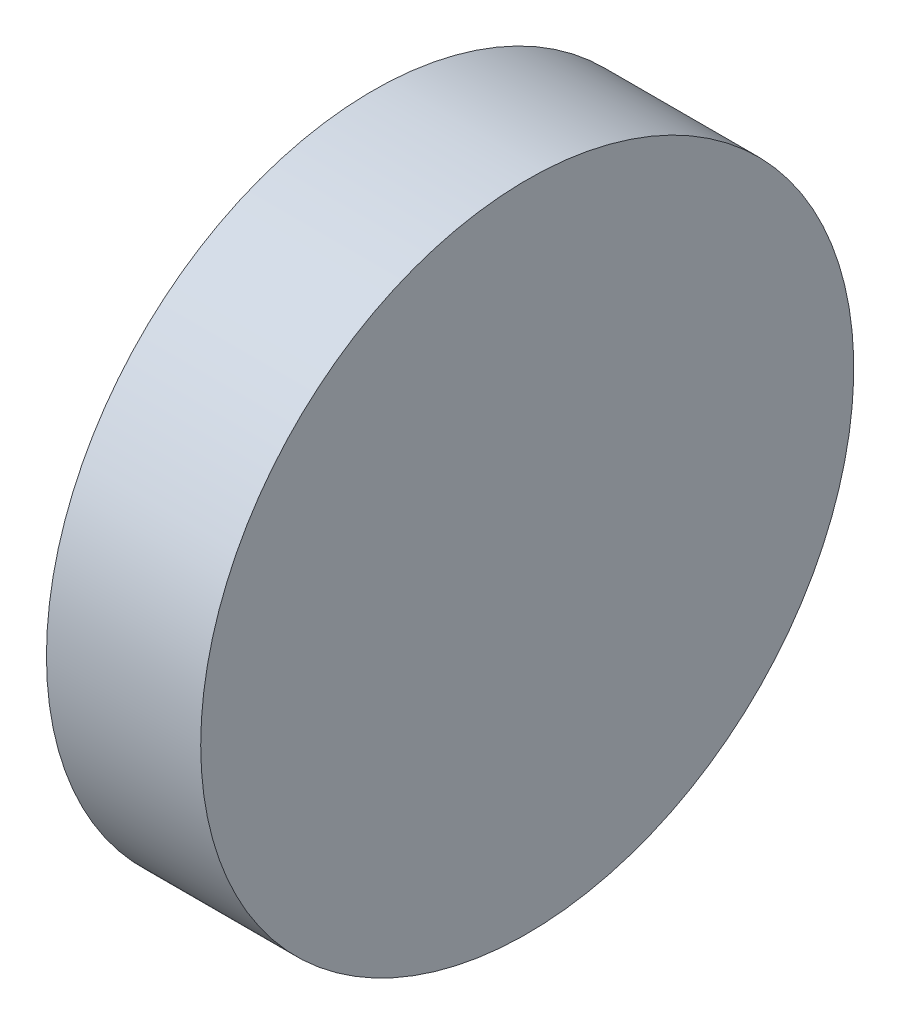
from build123d import *

# Parameters (mm, degrees)
SKETCH_1_W = 3
SKETCH_1_H = 6.35


with BuildPart() as part:
    # 草图1 → 旋转2 (revolve)
    with BuildSketch(Plane.XY, mode=Mode.PRIVATE) as revolve_2_sk:
        with Locations((1.5, 3.175)):
            Rectangle(SKETCH_1_W, SKETCH_1_H)
    revolve(revolve_2_sk.sketch.rotate(Axis((0, 0, 0), (1, 0, 0)), 90), axis=Axis((0, 0, 0), (1, 0, 0)))  # turned: the seam where the file's is


solid = part.part
